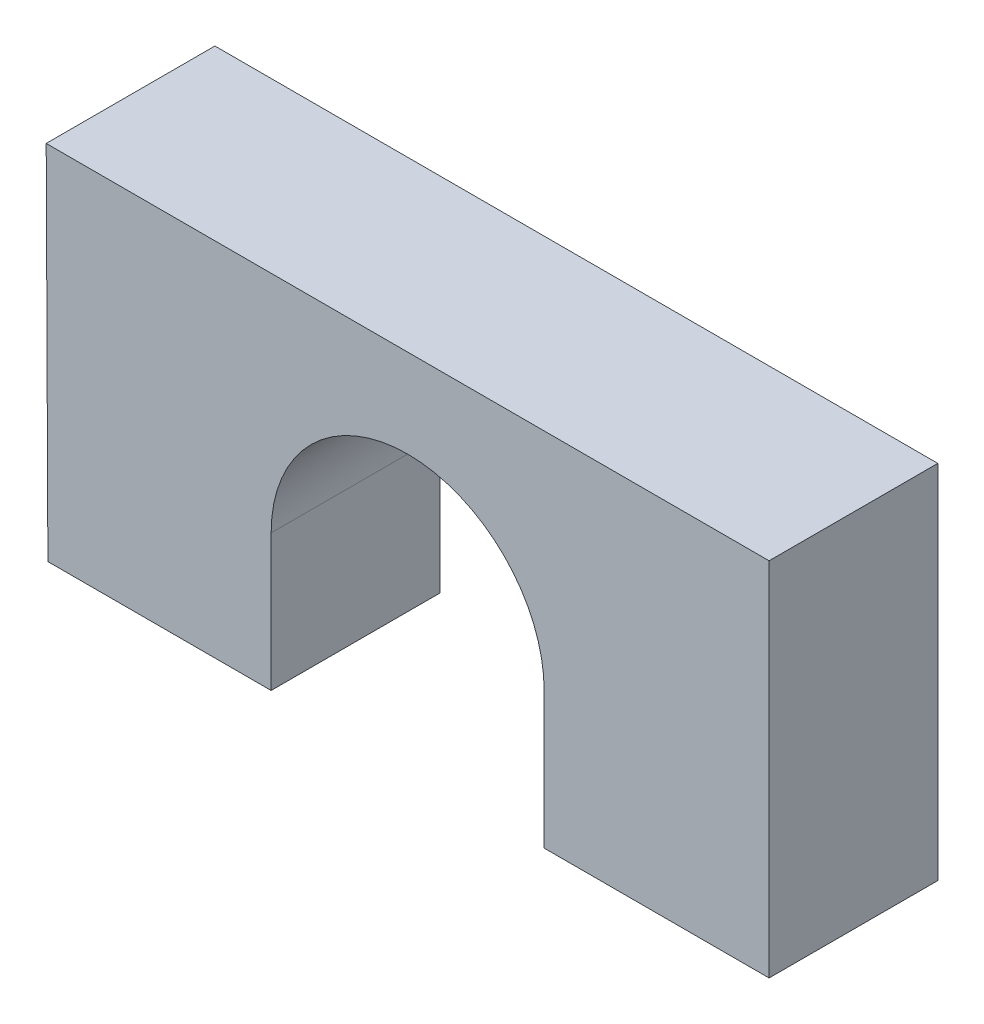
from build123d import *

# Parameters (mm, degrees)
BOSS_EXTRUDE2_DEPTH = 6


with BuildPart() as part:
    # Sketch1 → Boss-Extrude2 (new body)
    with BuildSketch(Plane.XY):
        with BuildLine():
            Line((-12.855, 7.995802232), (-12.794810638, -4.855))
            Line((-12.794810638, -4.855), (-4.855, -4.855))
            Line((-4.855, -4.855), (-4.855, 0))
            ThreePointArc((-4.855, 0), (0, 4.855), (4.855, 0))
            Line((4.855, 0), (4.855, -4.855))
            Line((4.855, -4.855), (12.855, -4.855))
            Line((12.855, -4.855), (12.855, 7.995802232))
            Line((12.855, 7.995802232), (-12.855, 7.995802232))
        make_face()
    extrude(amount=BOSS_EXTRUDE2_DEPTH)


solid = part.part
